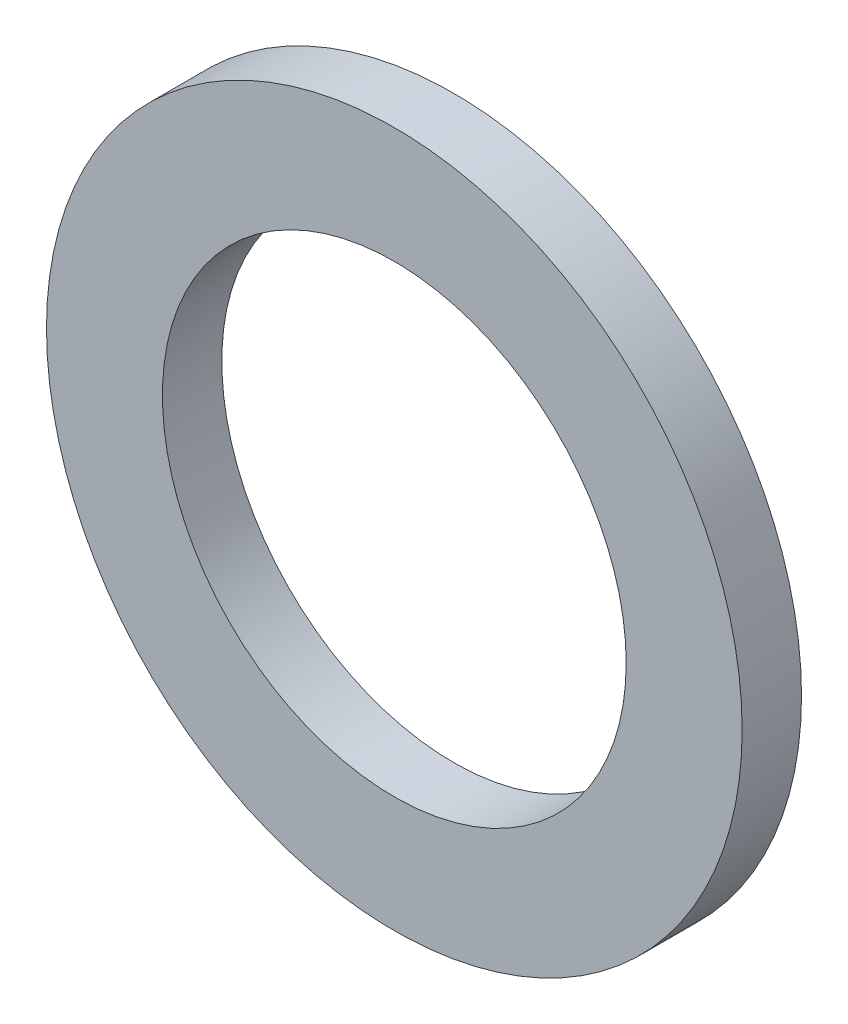
from build123d import *

# Parameters (mm, degrees)
SKETCH3_R           = 2.38125
SKETCH3_R_2         = 1.5875
BOSS_EXTRUDE1_DEPTH = 0.2032


with BuildPart() as part:
    # Sketch3 → Boss-Extrude1 (new, symmetric)
    with BuildSketch(Plane.XY):
        Circle(SKETCH3_R)
        Circle(SKETCH3_R_2, mode=Mode.SUBTRACT)
    extrude(amount=BOSS_EXTRUDE1_DEPTH, both=True)


solid = part.part
